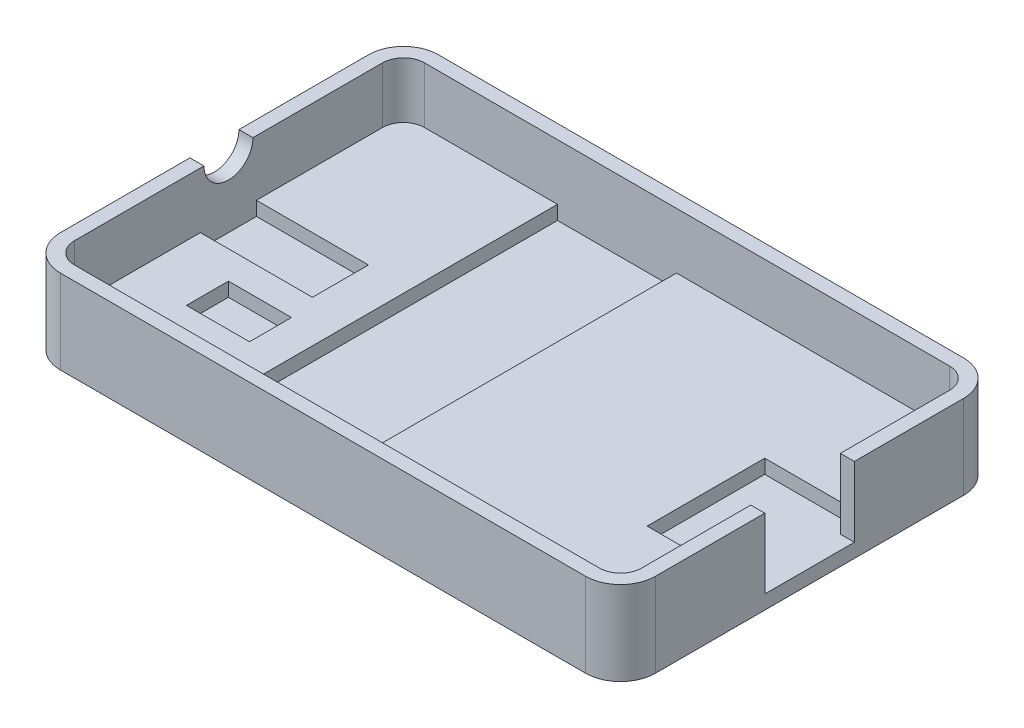
from build123d import *

# Parameters (mm, degrees)
SKETCH1_W           = 42.5
SKETCH1_H           = 27
BOSS_EXTRUDE1_DEPTH = 6
SKETCH2_W           = 40.5
SKETCH2_H           = 25
CUT_EXTRUDE1_DEPTH  = 4
SKETCH3_W           = 6.4
SKETCH3_H           = 6.4
CUT_EXTRUDE2_DEPTH  = 5
CUT_EXTRUDE3_REACH  = 44.5
SKETCH4_R           = 1.75
SKETCH5_W           = 8.5
SKETCH5_H           = 25
CUT_EXTRUDE4_DEPTH  = 1
SKETCH6_W           = 8
SKETCH6_H           = 4
CUT_EXTRUDE5_DEPTH  = 1
SKETCH7_W           = 4.5
SKETCH7_H           = 3
CUT_EXTRUDE6_DEPTH  = 1
FILLET1_R           = 1.5
FILLET2_R           = 2.5
SKETCH8_W           = 6.4
SKETCH8_H           = 8.4
CUT_EXTRUDE7_DEPTH  = 1


with BuildPart() as part:
    # Sketch1 → Boss-Extrude1 (new body)
    with BuildSketch(Plane(origin=(0, 0, 0), x_dir=(1, 0, 0), z_dir=(0, 1, 0))):
        Rectangle(SKETCH1_W, SKETCH1_H)
    extrude(amount=BOSS_EXTRUDE1_DEPTH)

    # Sketch2 → Cut-Extrude1 (cut)
    with BuildSketch(Plane(origin=(0, 6, 0), x_dir=(1, 0, 0), z_dir=(0, 1, 0))):
        Rectangle(SKETCH2_W, SKETCH2_H)
    extrude(amount=-CUT_EXTRUDE1_DEPTH, mode=Mode.SUBTRACT)

    # Sketch3 → Cut-Extrude2 (cut)
    with BuildSketch(Plane(origin=(0, 6, 0), x_dir=(1, 0, 0), z_dir=(0, 1, 0))):
        with Locations((18.05, 0)):
            Rectangle(SKETCH3_W, SKETCH3_H)
    extrude(amount=-CUT_EXTRUDE2_DEPTH, mode=Mode.SUBTRACT)

    # Sketch4 → Cut-Extrude3 (cut, up to next)
    with BuildSketch(Plane.ZY.offset(21.25), mode=Mode.PRIVATE) as cut_extrude3_sk1:
        with Locations((0, 6)):
            Circle(SKETCH4_R)
    cut_extrude3_tool1 = extrude(cut_extrude3_sk1.sketch, amount=-CUT_EXTRUDE3_REACH, mode=Mode.PRIVATE) & part.part
    add(cut_extrude3_tool1.solids().sort_by_distance((-21.25, 6, 0))[0], mode=Mode.SUBTRACT)

    # Sketch5 → Cut-Extrude4 (cut)
    with BuildSketch(Plane(origin=(0, 2, 0), x_dir=(1, 0, 0), z_dir=(0, 1, 0))):
        with Locations((-5, 0)):
            Rectangle(SKETCH5_W, SKETCH5_H)
    extrude(amount=-CUT_EXTRUDE4_DEPTH, mode=Mode.SUBTRACT)

    # Sketch6 → Cut-Extrude5 (cut)
    with BuildSketch(Plane(origin=(0, 2, 0), x_dir=(1, 0, 0), z_dir=(0, 1, 0))):
        with Locations((-16.25, 0)):
            Rectangle(SKETCH6_W, SKETCH6_H)
    extrude(amount=-CUT_EXTRUDE5_DEPTH, mode=Mode.SUBTRACT)

    # Sketch7 → Cut-Extrude6 (cut)
    with BuildSketch(Plane(origin=(0, 2, 0), x_dir=(1, 0, 0), z_dir=(0, 1, 0))):
        with Locations((-14, -5.5)):
            Rectangle(SKETCH7_W, SKETCH7_H)
    extrude(amount=-CUT_EXTRUDE6_DEPTH, mode=Mode.SUBTRACT)

    # Fillet1
    fillet1_edges = [part.edges().sort_by_distance(p)[0] for p in [
        (20.25, 4, -12.5),
        (20.25, 4, 12.5),
        (-20.25, 4, 12.5),
        (-20.25, 4, -12.5),
    ]]
    fillet(fillet1_edges, radius=FILLET1_R)

    # Fillet2
    fillet2_edges = [part.edges().sort_by_distance(p)[0] for p in [
        (21.25, 3, 13.5),
        (-21.25, 3, 13.5),
        (-21.25, 3, -13.5),
        (21.25, 3, -13.5),
    ]]
    fillet(fillet2_edges, radius=FILLET2_R)

    # Sketch8 → Cut-Extrude7 (cut)
    with BuildSketch(Plane(origin=(0, 2, 0), x_dir=(1, 0, 0), z_dir=(0, 1, 0))):
        with Locations((17.05, 0)):
            Rectangle(SKETCH8_W, SKETCH8_H)
    extrude(amount=-CUT_EXTRUDE7_DEPTH, mode=Mode.SUBTRACT)


solid = part.part
